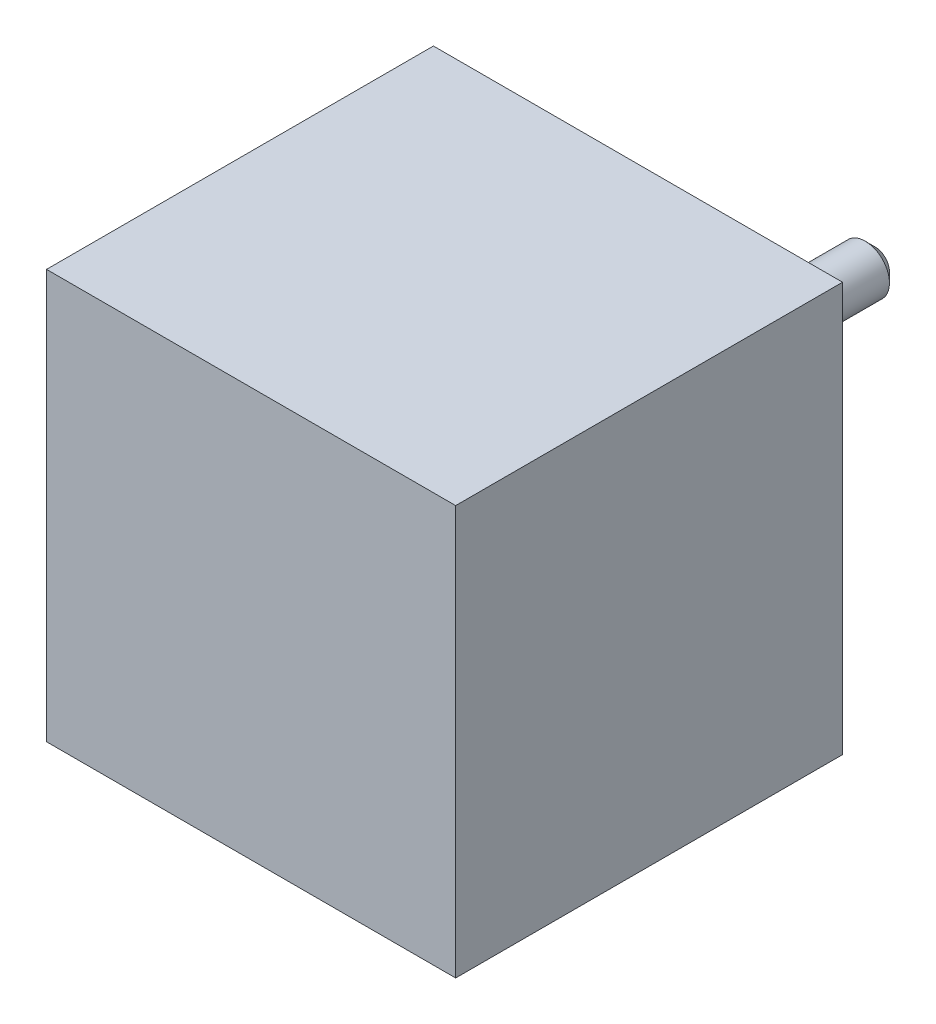
from build123d import *

# Parameters (mm, degrees)
SKIZZE1_W                       = 42.3
SKIZZE1_H                       = 42.3
AUFSATZ_LINEAR_AUSTRAGEN1_DEPTH = 40
SKIZZE2_R                       = 11
AUFSATZ_LINEAR_AUSTRAGEN2_DEPTH = 2
SKIZZE3_R                       = 2.5
AUFSATZ_LINEAR_AUSTRAGEN3_DEPTH = 22.5
FASE1_SIZE                      = 1
SKIZZE4_R                       = 1.25
SCHNITT_LINEAR_AUSTRAGEN1_DEPTH = 4.5


with BuildPart() as part:
    # Skizze1 → Aufsatz-Linear austragen1 (new body)
    with BuildSketch(Plane.XY):
        with Locations((21.15, 21.15)):
            Rectangle(SKIZZE1_W, SKIZZE1_H)
    extrude(amount=AUFSATZ_LINEAR_AUSTRAGEN1_DEPTH)

    # Skizze2 → Aufsatz-Linear austragen2 (add)
    with BuildSketch(Plane(origin=(0, 0, 0), x_dir=(-1, 0, 0), z_dir=(0, 0, -1))):
        with Locations((-21.15, 21.15)):
            Circle(SKIZZE2_R)
    extrude(amount=AUFSATZ_LINEAR_AUSTRAGEN2_DEPTH)

    # Skizze3 → Aufsatz-Linear austragen3 (add)
    with BuildSketch(Plane(origin=(0, 0, -2), x_dir=(-1, 0, 0), z_dir=(0, 0, -1))):
        with Locations((-21.15, 21.15)):
            Circle(SKIZZE3_R)
    extrude(amount=AUFSATZ_LINEAR_AUSTRAGEN3_DEPTH)

    # Fase1
    fase1_edges = [part.edges().sort_by_distance(p)[0] for p in [
        (23.65, 21.15, -24.5),
    ]]
    chamfer(fase1_edges, length=FASE1_SIZE)

    # Skizze4 → Schnitt-Linear austragen1 (cut)
    with BuildSketch(Plane(origin=(0, 0, 0), x_dir=(-1, 0, 0), z_dir=(0, 0, -1))):
        with Locations((-5.65, 36.65)):
            Circle(SKIZZE4_R)
        with Locations((-5.65, 5.65)):
            Circle(SKIZZE4_R)
        with Locations((-36.65, 5.65)):
            Circle(SKIZZE4_R)
        with Locations((-36.65, 36.65)):
            Circle(SKIZZE4_R)
    extrude(amount=-SCHNITT_LINEAR_AUSTRAGEN1_DEPTH, mode=Mode.SUBTRACT)


solid = part.part
